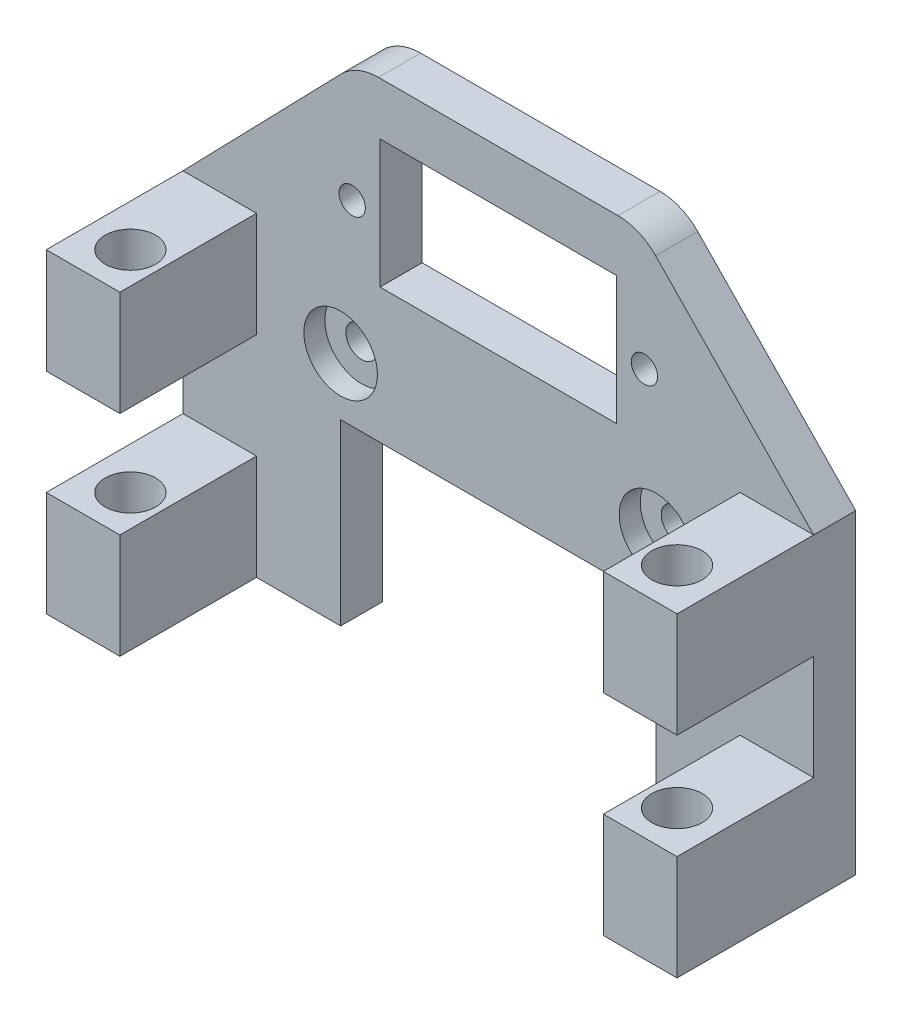
from build123d import *

# Parameters (mm, degrees)
EXTRUDE_1_DEPTH          = 4
SKETCH_2_R               = 1.25
SKETCH_2_R_2             = 1.5
SKETCH_2_W               = 22.5
SKETCH_2_H               = 12.2
CUT_EXTRUDE_1_DEPTH      = 5
SKETCH_3_W               = 7
SKETCH_3_H               = 13
EXTRUDE_2_DEPTH          = 13
SKETCH_4_R               = 2.15
CUT_EXTRUDE_2_DEPTH      = 1
CUT_EXTRUDE_2_DEPTH_BACK = 31
FILLET_3_R               = 5
SKETCH_5_R               = 3.5
CUT_EXTRUDE_3_DEPTH      = 2
SKETCH_6_W               = 7
SKETCH_6_H               = 3
CUT_EXTRUDE_4_DEPTH      = 13
SKETCH_7_W               = 15
SKETCH_7_H               = 17
EXTRUDE_3_DEPTH          = 4
SKETCH_8_W               = 7
SKETCH_8_H               = 10
EXTRUDE_4_DEPTH          = 13
SKETCH_9_R               = 2.4
CUT_EXTRUDE_5_DEPTH      = 48


with BuildPart() as part:
    # 草图1 → 凸台-拉伸1 (new body)
    with BuildSketch(Plane.XY):
        Polygon((-30, -15), (30, -15), (30, -2), (13.5, 15), (-13.5, 15), (-30, -2), align=None)
    extrude(amount=EXTRUDE_1_DEPTH)

    # 草图2 → 切除-拉伸1 (cut, through all)
    with BuildSketch(Plane.XY.offset(4)):
        with Locations((-13.9, 3.610655805)):
            Circle(SKETCH_2_R)
        with Locations((13.9, 3.610655805)):
            Circle(SKETCH_2_R)
        with Locations((-15, -9.553859164)):
            Circle(SKETCH_2_R_2)
        with Locations((15, -9.553859164)):
            Circle(SKETCH_2_R_2)
        with Locations((0, 3.9)):
            Rectangle(SKETCH_2_W, SKETCH_2_H)
    extrude(amount=-CUT_EXTRUDE_1_DEPTH, mode=Mode.SUBTRACT)

    # 草图3 → 凸台-拉伸2 (add)
    with BuildSketch(Plane.XY.offset(4)):
        with Locations((-26.5, -8.5)):
            Rectangle(SKETCH_3_W, SKETCH_3_H)
        with Locations((26.5, -8.5)):
            Rectangle(SKETCH_3_W, SKETCH_3_H)
    extrude(amount=EXTRUDE_2_DEPTH)

    # 草图4 → 切除-拉伸2 (cut, two sides)
    with BuildSketch(Plane(origin=(0, -15, 0), x_dir=(-1, 0, 0), z_dir=(0, -1, 0))) as cut_extrude_2_sk:
        with Locations((26, -13)):
            Circle(SKETCH_4_R)
        with Locations((-26, -13)):
            Circle(SKETCH_4_R)
    extrude(amount=CUT_EXTRUDE_2_DEPTH, mode=Mode.SUBTRACT)
    extrude(cut_extrude_2_sk.sketch, amount=-CUT_EXTRUDE_2_DEPTH_BACK, mode=Mode.SUBTRACT)

    # 圆角3
    fillet_3_edges = [part.edges().sort_by_distance(p)[0] for p in [
        (-13.5, 15, 2),
        (13.5, 15, 2),
    ]]
    fillet(fillet_3_edges, radius=FILLET_3_R)

    # 草图5 → 切除-拉伸3 (cut)
    with BuildSketch(Plane.XY.offset(4)):
        with Locations((-15, -9.553859164)):
            Circle(SKETCH_5_R)
        with Locations((15, -9.553859164)):
            Circle(SKETCH_5_R)
    extrude(amount=-CUT_EXTRUDE_3_DEPTH, mode=Mode.SUBTRACT)

    # 草图6 → 切除-拉伸4 (cut)
    with BuildSketch(Plane.XY.offset(17)):
        with Locations((-26.5, -13.5)):
            Rectangle(SKETCH_6_W, SKETCH_6_H)
        with Locations((26.5, -13.5)):
            Rectangle(SKETCH_6_W, SKETCH_6_H)
    extrude(amount=-CUT_EXTRUDE_4_DEPTH, mode=Mode.SUBTRACT)

    # 草图7 → 凸台-拉伸3 (add)
    with BuildSketch(Plane.XY.offset(4)):
        with Locations((-22.5, -23.5)):
            Rectangle(SKETCH_7_W, SKETCH_7_H)
        with Locations((22.5, -23.5)):
            Rectangle(SKETCH_7_W, SKETCH_7_H)
    extrude(amount=-EXTRUDE_3_DEPTH)

    # 草图8 → 凸台-拉伸4 (add)
    with BuildSketch(Plane.XY.offset(4)):
        with Locations((-26.5, -27)):
            Rectangle(SKETCH_8_W, SKETCH_8_H)
        with Locations((26.5, -27)):
            Rectangle(SKETCH_8_W, SKETCH_8_H)
    extrude(amount=EXTRUDE_4_DEPTH)

    # 草图9 → 切除-拉伸5 (cut, through all)
    with BuildSketch(Plane.XZ.offset(32)):
        with Locations((-26, 13)):
            Circle(SKETCH_9_R)
        with Locations((26, 13)):
            Circle(SKETCH_9_R)
    extrude(amount=-CUT_EXTRUDE_5_DEPTH, mode=Mode.SUBTRACT)


solid = part.part
